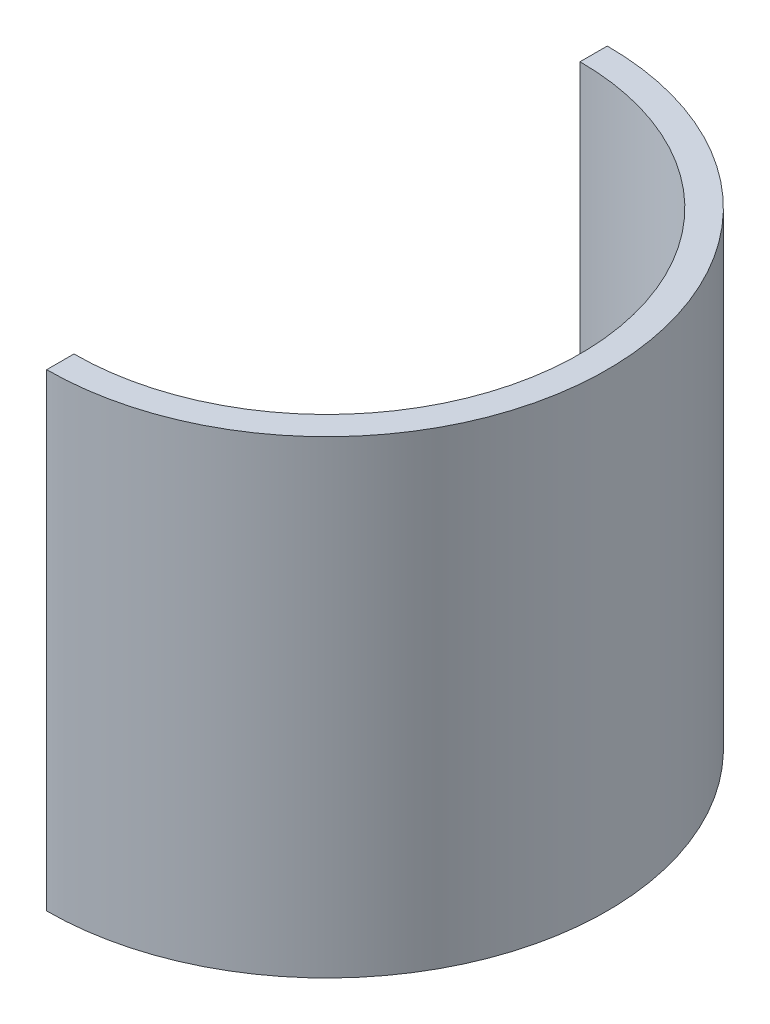
from build123d import *

# Parameters (mm, degrees)
SKETCH_1_W = 5
SKETCH_1_H = 86


with BuildPart() as part:
    # 扫描1: sweep along a path in 草图2
    with BuildLine(Plane(origin=(0, 0, 0), x_dir=(1, 0, 0), z_dir=(0, 1, 0))) as sweep_1_path:
        ThreePointArc((0, -83.689360979), (46.425, -37.264360979), (0, 9.160639021))
    # 草图1 → 扫描1 (sweep)
    with BuildSketch(Plane(origin=(0, 0, 0), x_dir=(0, 0, -1), z_dir=(1, 0, 0))):
        with Locations((11.660639021, 0.487561787)):
            Rectangle(SKETCH_1_W, SKETCH_1_H)
    sweep(path=sweep_1_path.line)


solid = part.part
